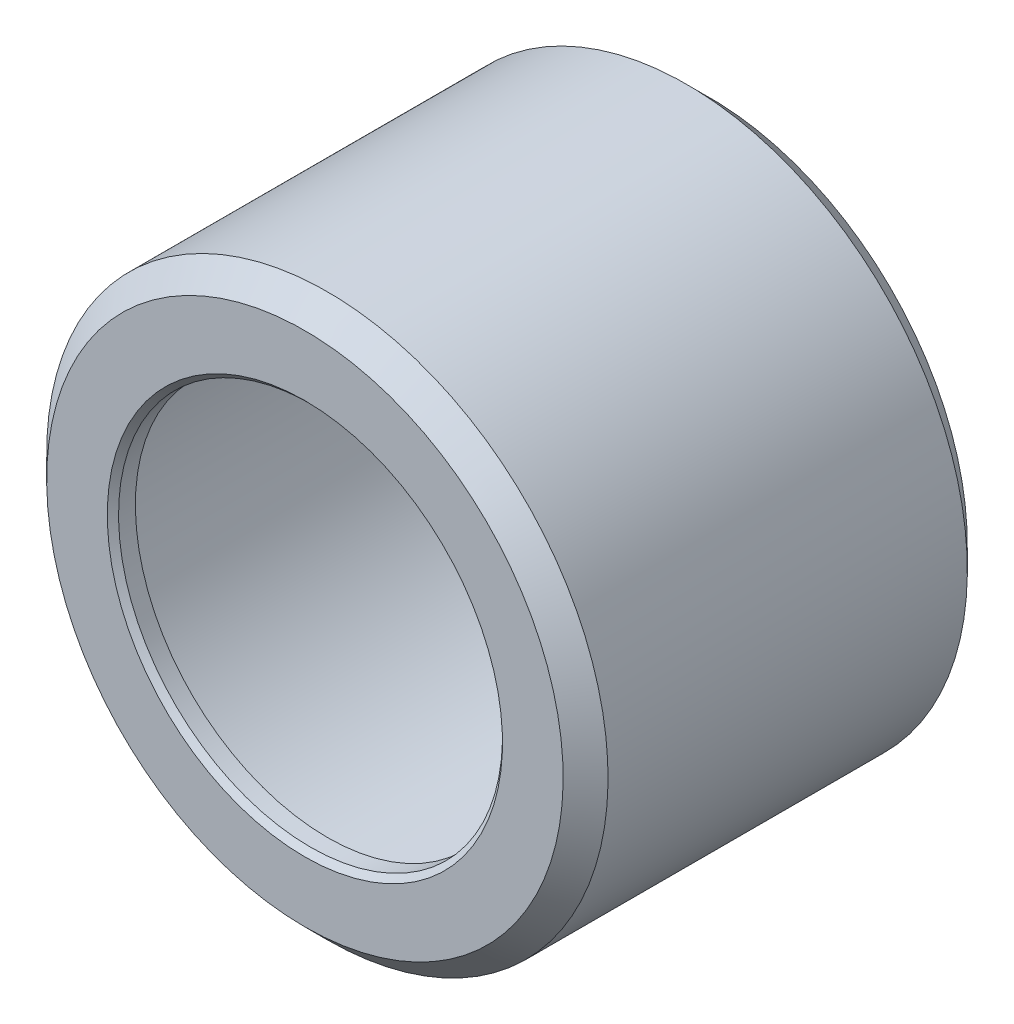
from build123d import *

# Parameters (mm, degrees)
SPESSORE1_T1 = 1
SMUSSO1_SIZE = 0.25


with BuildPart() as body_1:
    # Superficie-Rivoluzione1: a surface, the sketch's curves turned about an axis
    with BuildLine(Plane(origin=(0, 0, 0), x_dir=(0, 0, -1), z_dir=(1, 0, 0)), mode=Mode.PRIVATE) as superficie_rivoluzione1_1_path:
        Line((-9, 8.55), (-9, 11.5))
        Line((-9, 11.5), (-8, 12.5))
        Line((-8, 12.5), (8, 12.5))
        Line((8, 12.5), (9, 11.5))
        Line((9, 11.5), (9, 8.55))
    superficie_rivoluzione1_1 = Shell.revolve(superficie_rivoluzione1_1_path.wire(), 360, Axis((0, 0, 0), (0, 0, 1)))
    add(Solid.thicken(superficie_rivoluzione1_1, SPESSORE1_T1))

    # Smusso1
    smusso1_edges = [body_1.edges().sort_by_distance(p)[0] for p in [
        (0, -8.55, -9),
        (0, -8.55, 9),
    ]]
    chamfer(smusso1_edges, length=SMUSSO1_SIZE)


solid = body_1.part
